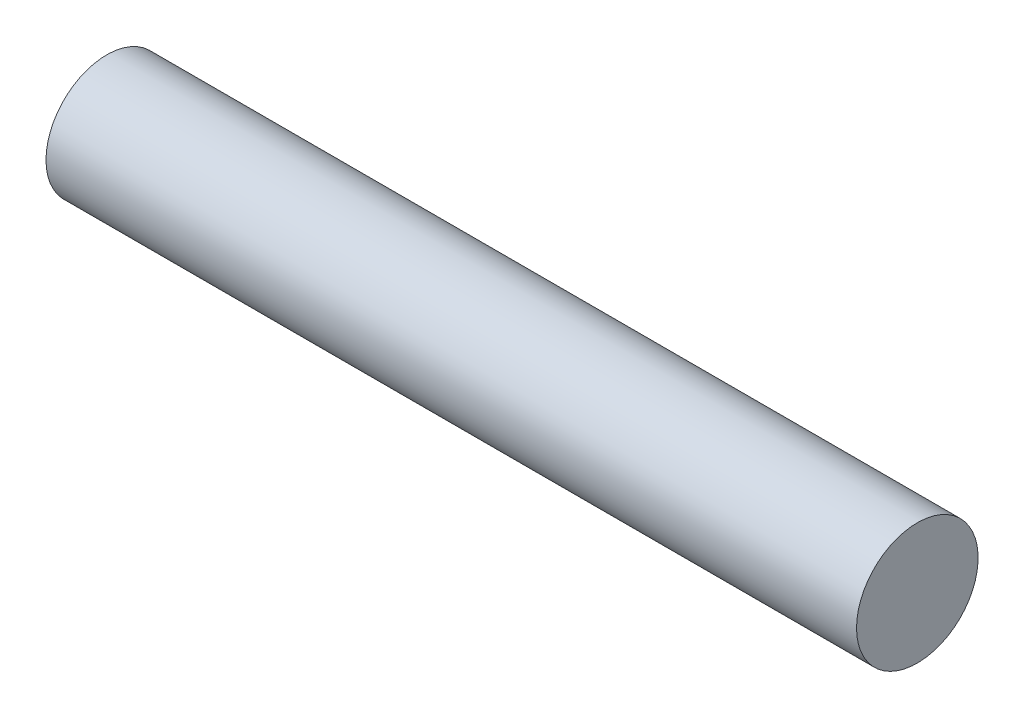
from build123d import *

# Parameters (mm, degrees)
SKETCH1_W = 60
SKETCH1_H = 4.5


with BuildPart() as part:
    # Sketch1 → Revolve-Thin1 (revolve)
    with BuildSketch(Plane.XY):
        with Locations((30, 2.25)):
            Rectangle(SKETCH1_W, SKETCH1_H)
    revolve(axis=Axis((0, 0, 0), (1, 0, 0)))


solid = part.part
